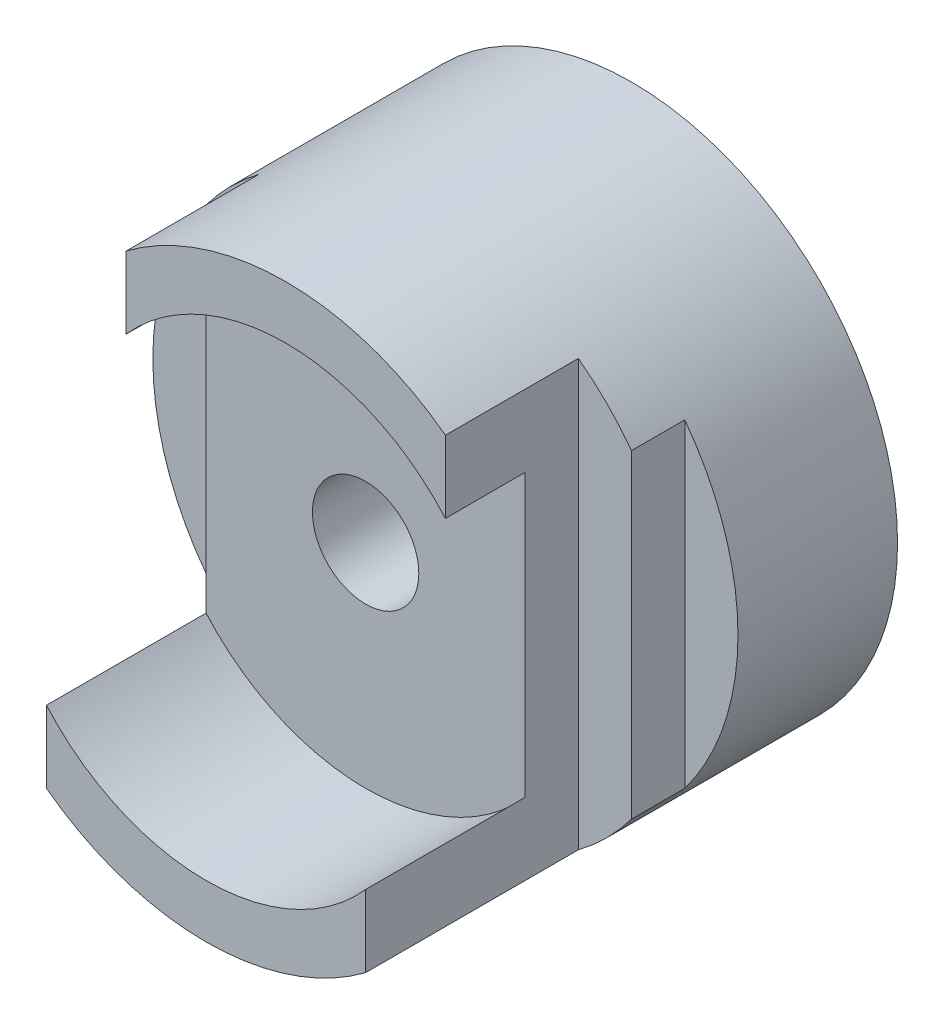
from build123d import *

# Parameters (mm, degrees)
SKETCH2_R           = 5
SKETCH2_R_2         = 1
BOSS_EXTRUDE1_DEPTH = 8
SKETCH3_W           = 1
SKETCH3_H           = 1
SKETCH3_W_2         = 2
SKETCH3_H_2         = 4
CUT_EXTRUDE1_DEPTH  = 4
SKETCH4_R           = 4
CUT_EXTRUDE2_DEPTH  = 3
SKETCH5_W           = 9.370112771
SKETCH5_H           = 5.033531654
CUT_EXTRUDE3_DEPTH  = 1.5


with BuildPart() as part:
    # Sketch2 → Boss-Extrude1 (new body)
    with BuildSketch(Plane.XY):
        Circle(SKETCH2_R)
        Circle(SKETCH2_R_2, mode=Mode.SUBTRACT)
    extrude(amount=BOSS_EXTRUDE1_DEPTH)

    # Sketch3 → Cut-Extrude1 (cut, symmetric)
    with BuildSketch(Plane(origin=(0, 0, 0), x_dir=(1, 0, 0), z_dir=(0, 1, 0))):
        with Locations((-4.5, -0.5)):
            Rectangle(SKETCH3_W, SKETCH3_H)
        Polygon((5, -8), (3, -8), (3, -4), (4, -4), (4, -3), (5, -3), align=None)
        with Locations((-4, -6)):
            Rectangle(SKETCH3_W_2, SKETCH3_H_2)
    extrude(amount=CUT_EXTRUDE1_DEPTH, both=True, mode=Mode.SUBTRACT)

    # Sketch4 → Cut-Extrude2 (cut)
    with BuildSketch(Plane.XY.offset(8)):
        Circle(SKETCH4_R)
    extrude(amount=-CUT_EXTRUDE2_DEPTH, mode=Mode.SUBTRACT)

    # Sketch5 → Cut-Extrude3 (cut)
    with BuildSketch(Plane.XY.offset(8)):
        with Locations((0.643727428, 3.756174823)):
            Rectangle(SKETCH5_W, SKETCH5_H)
    extrude(amount=-CUT_EXTRUDE3_DEPTH, mode=Mode.SUBTRACT)


solid = part.part
